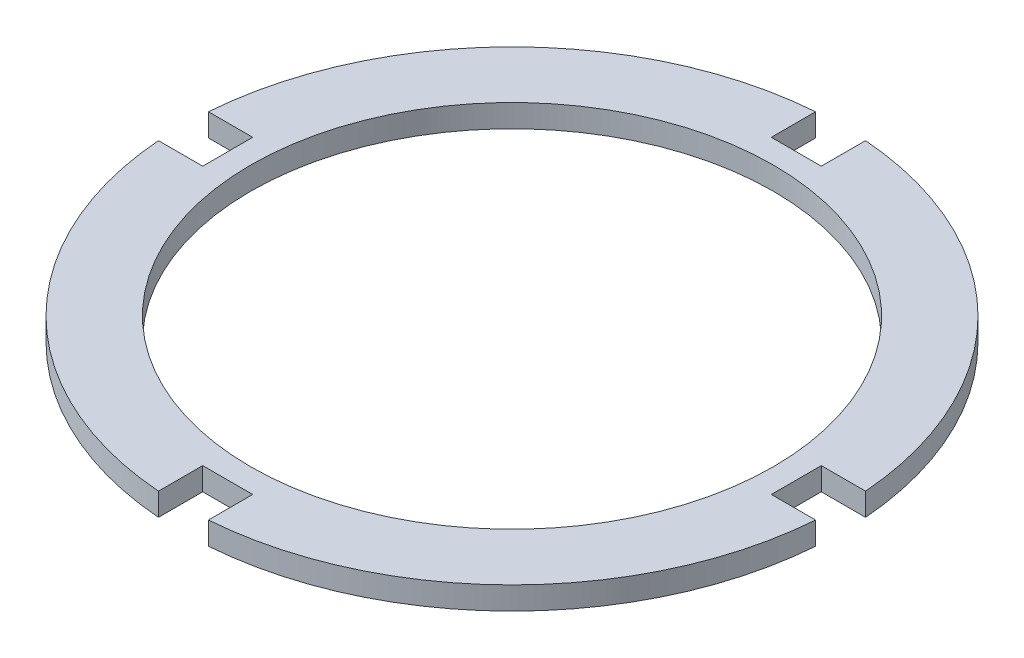
from build123d import *

# Parameters (mm, degrees)
SKETCH1_R           = 73.025
BOSS_EXTRUDE1_DEPTH = 6.35


with BuildPart() as part:
    # Sketch1 → Boss-Extrude1 (new body)
    with BuildSketch(Plane(origin=(0, 0, 0), x_dir=(1, 0, 0), z_dir=(0, 1, 0))):
        with BuildLine():
            Line((79.44104, 6.985), (91.809669425, 6.985))
            ThreePointArc((91.809669425, 6.985), (65.106856878, 65.106856878), (6.985, 91.809669425))
            Line((6.985, 91.809669425), (6.985, 79.44104))
            Line((6.985, 79.44104), (-6.985, 79.44104))
            Line((-6.985, 79.44104), (-6.985, 91.809669425))
            ThreePointArc((-6.985, 91.809669425), (-65.106856878, 65.106856878), (-91.809669425, 6.985))
            Line((-91.809669425, 6.985), (-79.44104, 6.985))
            Line((-79.44104, 6.985), (-79.44104, -6.985))
            Line((-79.44104, -6.985), (-91.809669425, -6.985))
            ThreePointArc((-91.809669425, -6.985), (-65.106856878, -65.106856878), (-6.985, -91.809669425))
            Line((-6.985, -91.809669425), (-6.985, -79.44104))
            Line((-6.985, -79.44104), (6.985, -79.44104))
            Line((6.985, -79.44104), (6.985, -91.809669425))
            ThreePointArc((6.985, -91.809669425), (65.106856878, -65.106856878), (91.809669425, -6.985))
            Line((91.809669425, -6.985), (79.44104, -6.985))
            Line((79.44104, -6.985), (79.44104, 6.985))
        make_face()
        Circle(SKETCH1_R, mode=Mode.SUBTRACT)
    extrude(amount=BOSS_EXTRUDE1_DEPTH)


solid = part.part
